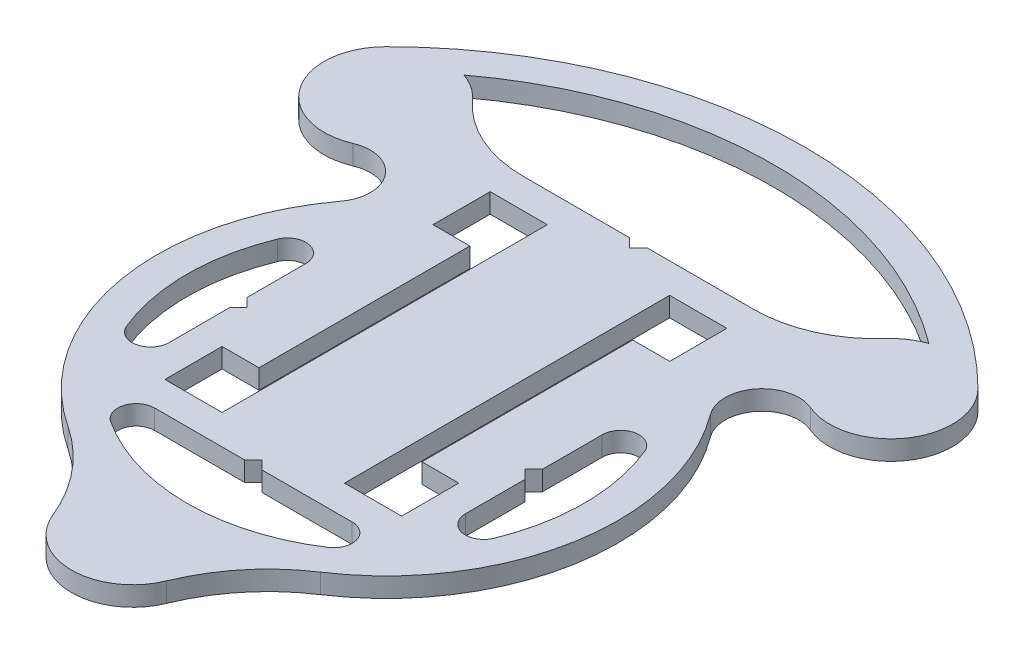
from build123d import *

# Parameters (mm, degrees)
BOSS_EXTRUDE1_DEPTH = 3.175
CUT_EXTRUDE3_REACH  = 81.562
CUT_EXTRUDE4_REACH  = 81.562


with BuildPart() as part:
    # Sketch1 → Boss-Extrude1 (new body)
    with BuildSketch(Plane(origin=(0, 0, 0), x_dir=(1, 0, 0), z_dir=(0, 1, 0))):
        with BuildLine():
            ThreePointArc((-48.171067812, 38.371067812), (0, 58.324177414), (48.171067812, 38.371067812))
            ThreePointArc((48.171067812, 38.371067812), (49.391561976, 25.709830056), (37.196595128, 22.093294269))
            ThreePointArc((37.196595128, 22.093294269), (30.138485199, 20.278544613), (30.037914527, 12.991561861))
            ThreePointArc((30.037914527, 12.991561861), (36.897831444, -16.018932904), (20.532641942, -40.935751303))
            ThreePointArc((20.532641942, -40.935751303), (13.857325378, -46.949439456), (9.262101932, -54.670075305))
            ThreePointArc((9.262101932, -54.670075305), (0, -60.9), (-9.262101932, -54.670075305))
            ThreePointArc((-9.262101932, -54.670075305), (-13.857325378, -46.949439456), (-20.532641942, -40.935751303))
            ThreePointArc((-20.532641942, -40.935751303), (-36.897831444, -16.018932904), (-30.037914527, 12.991561861))
            ThreePointArc((-30.037914527, 12.991561861), (-30.138485199, 20.278544613), (-37.196595128, 22.093294269))
            ThreePointArc((-37.196595128, 22.093294269), (-49.391561976, 25.709830056), (-48.171067812, 38.371067812))
        make_face()
        with BuildLine():
            Line((-18.739320225, 31.3), (18.739320225, 31.3))
            ThreePointArc((18.739320225, 31.3), (26.904286034, 33.042581416), (33.646440075, 37.966666667))
            ThreePointArc((33.646440075, 37.966666667), (35.5534685, 39.620816565), (37.813975674, 40.744683379))
            ThreePointArc((37.813975674, 40.744683379), (0, 53.324177414), (-37.813975674, 40.744683379))
            ThreePointArc((-37.813975674, 40.744683379), (-35.5534685, 39.620816565), (-33.646440075, 37.966666667))
            ThreePointArc((-33.646440075, 37.966666667), (-26.904286034, 33.042581416), (-18.739320225, 31.3))
        make_face(mode=Mode.SUBTRACT)
        with BuildLine():
            Line((-24.1, -20.929751273), (-24.120801343, 1.682420185))
            ThreePointArc((-24.120801343, 1.682420185), (-26.693463619, 4.302078337), (-29.875081258, 2.469454748))
            ThreePointArc((-29.875081258, 2.469454748), (-32.296439432, -9.8), (-29.875081258, -22.069454748))
            ThreePointArc((-29.875081258, -22.069454748), (-26.519157411, -23.87298451), (-24.1, -20.929751273))
        make_face(mode=Mode.SUBTRACT)
        with BuildLine():
            Line((24.1, -20.929751273), (24.1, 1.329751273))
            ThreePointArc((24.1, 1.329751273), (26.519157411, 4.27298451), (29.875081258, 2.469454748))
            ThreePointArc((29.875081258, 2.469454748), (32.296439432, -9.8), (29.875081258, -22.069454748))
            ThreePointArc((29.875081258, -22.069454748), (26.519157411, -23.87298451), (24.1, -20.929751273))
        make_face(mode=Mode.SUBTRACT)
        with BuildLine():
            Line((-16.063354675, -31.3), (16.063354675, -31.3))
            ThreePointArc((16.063354675, -31.3), (18.937942636, -33.441662042), (17.708266649, -36.8088373))
            ThreePointArc((17.708266649, -36.8088373), (0, -42.096439432), (-17.708266649, -36.8088373))
            ThreePointArc((-17.708266649, -36.8088373), (-18.937942636, -33.441662042), (-16.063354675, -31.3))
        make_face(mode=Mode.SUBTRACT)
    extrude(amount=BOSS_EXTRUDE1_DEPTH)

    # Sketch2 → Cut-Extrude3 (cut, up to next)
    with BuildSketch(Plane(origin=(0, 3.175, 0), x_dir=(1, 0, 0), z_dir=(0, 1, 0)), mode=Mode.PRIVATE) as cut_extrude3_sk1:
        Polygon((-19.25, -17.15), (-13.25, -17.15), (-13.25, 17.15), (-19.25, 17.15), (-19.25, 26.45), (-9.95, 26.45), (-9.95, -26.45), (-19.25, -26.45), align=None)
    cut_extrude3_tool1 = extrude(cut_extrude3_sk1.sketch, amount=-CUT_EXTRUDE3_REACH, mode=Mode.PRIVATE) & part.part
    # Sketch2 → Cut-Extrude3 (cut, up to next)
    with BuildSketch(Plane(origin=(0, 3.175, 0), x_dir=(1, 0, 0), z_dir=(0, 1, 0)), mode=Mode.PRIVATE) as cut_extrude3_sk2:
        Polygon((19.25, -17.15), (13.25, -17.15), (13.25, 17.15), (19.25, 17.15), (19.25, 26.45), (9.95, 26.45), (9.95, -26.45), (19.25, -26.45), align=None)
    cut_extrude3_tool2 = extrude(cut_extrude3_sk2.sketch, amount=-CUT_EXTRUDE3_REACH, mode=Mode.PRIVATE) & part.part
    add(cut_extrude3_tool1.solids().sort_by_distance((-16.25, 3.175, 17.687113))[0], mode=Mode.SUBTRACT)
    add(cut_extrude3_tool2.solids().sort_by_distance((16.25, 3.175, 17.687113))[0], mode=Mode.SUBTRACT)

    # Sketch8 → Cut-Extrude4 (cut, up to next)
    with BuildSketch(Plane(origin=(0, 3.175, 0), x_dir=(1, 0, 0), z_dir=(0, 1, 0)), mode=Mode.PRIVATE) as cut_extrude4_sk1:
        Polygon((-22.702010907, -9.63396598), (-24.111696309, -8.21523871), (-24.109105034, -11.032092379), align=None)
    cut_extrude4_tool1 = extrude(cut_extrude4_sk1.sketch, amount=-CUT_EXTRUDE4_REACH, mode=Mode.PRIVATE) & part.part
    # Sketch8 → Cut-Extrude4 (cut, up to next)
    with BuildSketch(Plane(origin=(0, 3.175, 0), x_dir=(1, 0, 0), z_dir=(0, 1, 0)), mode=Mode.PRIVATE) as cut_extrude4_sk2:
        Polygon((22.685786438, -9.8), (24.1, -11.214213562), (24.1, -8.385786438), align=None)
    cut_extrude4_tool2 = extrude(cut_extrude4_sk2.sketch, amount=-CUT_EXTRUDE4_REACH, mode=Mode.PRIVATE) & part.part
    # Sketch8 → Cut-Extrude4 (cut, up to next)
    with BuildSketch(Plane(origin=(0, 3.175, 0), x_dir=(1, 0, 0), z_dir=(0, 1, 0)), mode=Mode.PRIVATE) as cut_extrude4_sk3:
        Polygon((0, -29.885786438), (-1.414213562, -31.3), (1.414213562, -31.3), align=None)
    cut_extrude4_tool3 = extrude(cut_extrude4_sk3.sketch, amount=-CUT_EXTRUDE4_REACH, mode=Mode.PRIVATE) & part.part
    # Sketch8 → Cut-Extrude4 (cut, up to next)
    with BuildSketch(Plane(origin=(0, 3.175, 0), x_dir=(1, 0, 0), z_dir=(0, 1, 0)), mode=Mode.PRIVATE) as cut_extrude4_sk4:
        Polygon((0, 29.885786438), (-1.414213562, 31.3), (1.414213562, 31.3), align=None)
    cut_extrude4_tool4 = extrude(cut_extrude4_sk4.sketch, amount=-CUT_EXTRUDE4_REACH, mode=Mode.PRIVATE) & part.part
    add(cut_extrude4_tool1.solids().sort_by_distance((-23.640937, 3.175, 9.627099))[0], mode=Mode.SUBTRACT)
    add(cut_extrude4_tool2.solids().sort_by_distance((23.628595, 3.175, 9.8))[0], mode=Mode.SUBTRACT)
    add(cut_extrude4_tool3.solids().sort_by_distance((0, 3.175, 30.828595))[0], mode=Mode.SUBTRACT)
    add(cut_extrude4_tool4.solids().sort_by_distance((0, 3.175, -30.828595))[0], mode=Mode.SUBTRACT)


solid = part.part
